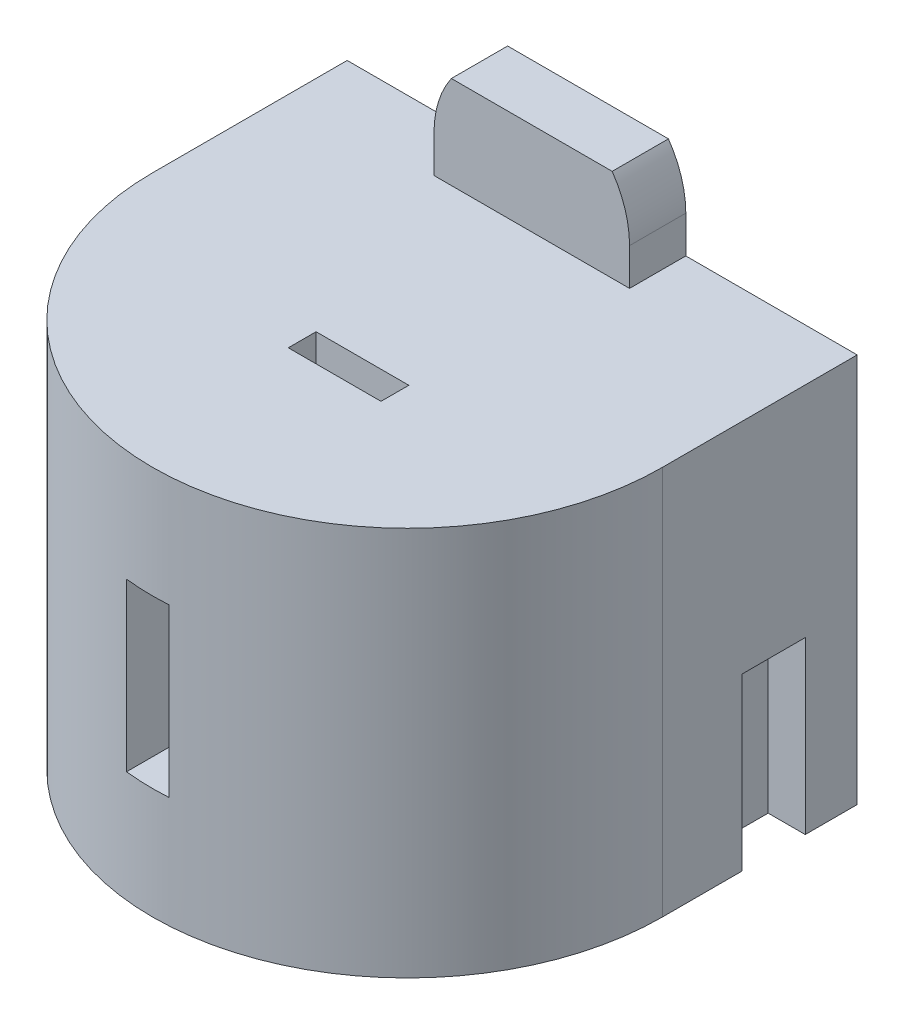
from build123d import *

# Parameters (mm, degrees)
REVOLVE_1_ANGLE     = 180
SKETCH_5_W          = 27.5
SKETCH_5_H          = 21
SKETCH_5_W_2        = 21.5
SKETCH_5_H_2        = 15
EXTRUDE_1_DEPTH     = 10.5
SKETCH_6_W          = 2.331495027
SKETCH_6_H          = 8.995198028
CUT_EXTRUDE_1_DEPTH = 14.75
SKETCH_7_W          = 5
SKETCH_7_H          = 1.5
CUT_EXTRUDE_2_DEPTH = 22
EXTRUDE_2_DEPTH     = 3.033498617
SKETCH_10_W         = 3.4
SKETCH_10_H         = 9.803428708
CUT_EXTRUDE_3_DEPTH = 2
SKETCH_11_W         = 3.4
SKETCH_11_H         = 10.345530218
CUT_EXTRUDE_4_DEPTH = 2


with BuildPart() as part:
    # Эскиз1 → Повернуть1 (revolve)
    with BuildSketch(Plane.XY):
        Polygon((-32.743084191, 13.975613819), (-18.993084191, 13.975613819), (-18.993084191, -7.024386181), (-32.743084191, -7.024386181), (-32.743084191, -4.024386181), (-21.993084191, -4.024386181), (-21.993084191, 10.975613819), (-32.743084191, 10.975613819), align=None)
    revolve(axis=Axis((-32.743084191, 13.975613819, 0), (0, -1, 0)), revolution_arc=REVOLVE_1_ANGLE)

    # Эскиз5 → Бобышка-Вытянуть1 (add)
    with BuildSketch(Plane(origin=(0, 0, 0), x_dir=(-1, 0, 0), z_dir=(0, 0, -1))):
        with Locations((32.743084191, 3.475613819)):
            Rectangle(SKETCH_5_W, SKETCH_5_H)
        with Locations((32.743084191, 3.475613819)):
            Rectangle(SKETCH_5_W_2, SKETCH_5_H_2, mode=Mode.SUBTRACT)
    extrude(amount=EXTRUDE_1_DEPTH)

    # Эскиз6 → Вырез-Вытянуть1 (cut, through all)
    with BuildSketch(Plane.XY):
        with Locations((-33.056054499, 3.475613819)):
            Rectangle(SKETCH_6_W, SKETCH_6_H)
    extrude(amount=CUT_EXTRUDE_1_DEPTH, mode=Mode.SUBTRACT)

    # Эскиз7 → Вырез-Вытянуть2 (cut, through all)
    with BuildSketch(Plane(origin=(0, 13.975613819, 0), x_dir=(1, 0, 0), z_dir=(0, 1, 0))):
        with Locations((-32.16223421, -3.7570716)):
            Rectangle(SKETCH_7_W, SKETCH_7_H)
    extrude(amount=-CUT_EXTRUDE_2_DEPTH, mode=Mode.SUBTRACT)

    # Эскиз10 → Вырез-Вытянуть3 (cut)
    with BuildSketch(Plane.ZY.offset(46.493084191)):
        with Locations((-6, -2.726100535)):
            Rectangle(SKETCH_10_W, SKETCH_10_H)
    extrude(amount=-CUT_EXTRUDE_3_DEPTH, mode=Mode.SUBTRACT)

    # Эскиз11 → Вырез-Вытянуть4 (cut)
    with BuildSketch(Plane(origin=(-18.993084191, 0, 0), x_dir=(0, 0, -1), z_dir=(1, 0, 0))):
        with Locations((6, -2.99715129)):
            Rectangle(SKETCH_11_W, SKETCH_11_H)
    extrude(amount=-CUT_EXTRUDE_4_DEPTH, mode=Mode.SUBTRACT)


with BuildPart() as body_2:
    # Эскиз9 → Бобышка-Вытянуть2 (new body)
    with BuildSketch(Plane(origin=(0, 0, -10.5), x_dir=(-1, 0, 0), z_dir=(0, 0, -1))):
        with BuildLine():
            Line((28.233170804, 15.974855989), (28.233170804, 13.97664863))
            Line((28.233170804, 13.97664863), (38.77838061, 13.974754187))
            Line((38.77838061, 13.974754187), (38.77838061, 15.974855989))
            ThreePointArc((38.77838061, 15.974855989), (38.538632142, 17.546707944), (37.841189748, 18.975613819))
            Line((37.841189748, 18.975613819), (29.170361666, 18.975613819))
            ThreePointArc((29.170361666, 18.975613819), (28.472919272, 17.546707944), (28.233170804, 15.974855989))
        make_face()
    extrude(amount=-EXTRUDE_2_DEPTH)


solid = Compound([part.part, body_2.part])
